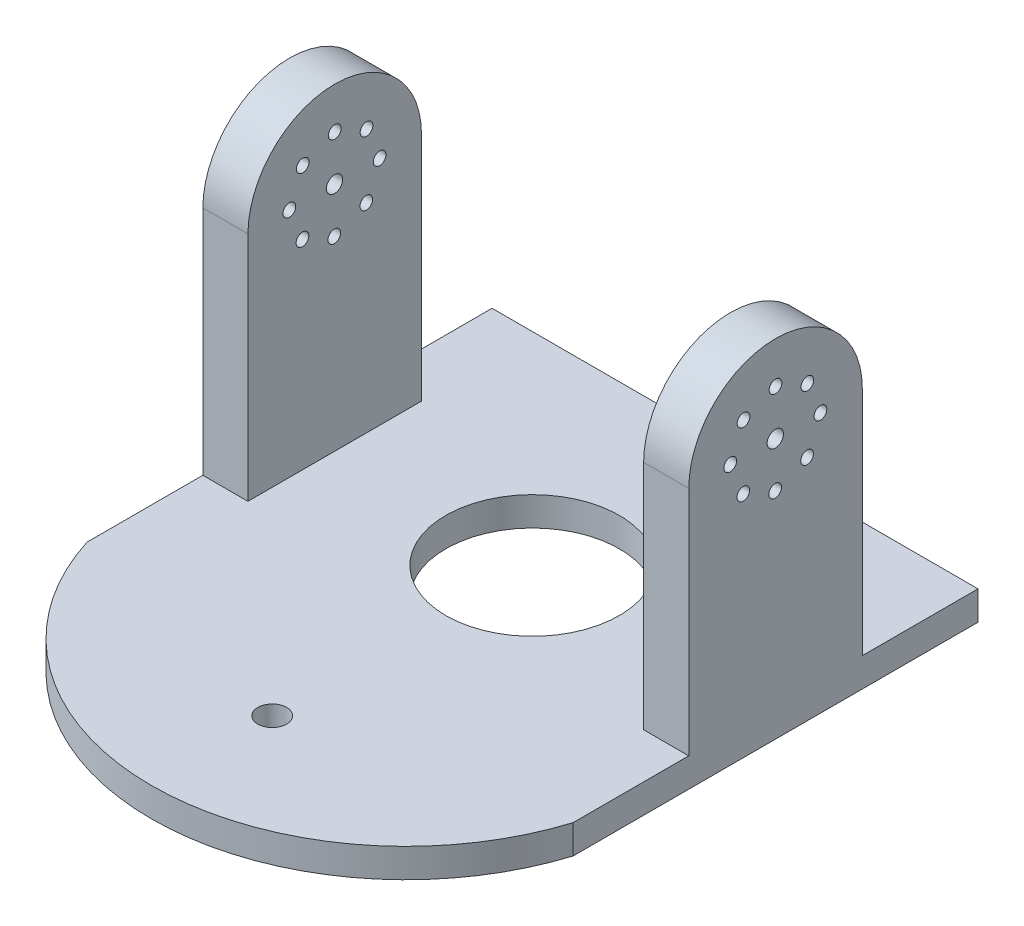
from build123d import *

# Parameters (mm, degrees)
SKETCH1_R           = 19.05
SKETCH1_R_2         = 3.175
BOSS_EXTRUDE1_DEPTH = 6.35
SKETCH6_W           = 9.906
SKETCH6_H           = 38.1
BOSS_EXTRUDE2_DEPTH = 76.2
SKETCH7_R           = 1.397
SKETCH7_R_2         = 1.7859375
CUT_EXTRUDE1_DEPTH  = 107.68


with BuildPart() as part:
    # Sketch1 → Boss-Extrude1 (new body)
    with BuildSketch(Plane(origin=(0, 0, 0), x_dir=(1, 0, 0), z_dir=(0, 1, 0))):
        with BuildLine():
            Line((-53.503176773, 44.45), (53.176823227, 44.45))
            Line((53.176823227, 44.45), (53.176823227, -44.45))
            ThreePointArc((53.176823227, -44.45), (-0.163176773, -83.674106148), (-53.503176773, -44.45))
            Line((-53.503176773, -44.45), (-53.503176773, 44.45))
        make_face()
        with Locations((-0.163176773, 0)):
            Circle(SKETCH1_R, mode=Mode.SUBTRACT)
        with Locations((-0.163176773, -57.15)):
            Circle(SKETCH1_R_2, mode=Mode.SUBTRACT)
    extrude(amount=BOSS_EXTRUDE1_DEPTH)

    # Sketch6 → Boss-Extrude2 (add)
    with BuildSketch(Plane(origin=(0, 6.35, 0), x_dir=(1, 0, 0), z_dir=(0, 1, 0))):
        with Locations((-48.550176773, 0)):
            Rectangle(SKETCH6_W, SKETCH6_H)
        with Locations((48.223823227, 0)):
            Rectangle(SKETCH6_W, SKETCH6_H)
    extrude(amount=BOSS_EXTRUDE2_DEPTH)

    # Sketch7 → Cut-Extrude1 (cut, through all)
    with BuildSketch(Plane.ZY.offset(53.503176773)):
        with Locations((-6.991480211, 64.122926346)):
            Circle(SKETCH7_R)
        with Locations((0, 67.056)):
            Circle(SKETCH7_R)
        with Locations((7.017719338, 64.186273203)):
            Circle(SKETCH7_R)
        with Locations((9.950792993, 57.194792993)):
            Circle(SKETCH7_R)
        with Locations((7.081066196, 50.177073654)):
            Circle(SKETCH7_R)
        with Locations((0.089585985, 47.244)):
            Circle(SKETCH7_R)
        with Locations((-6.928133353, 50.113726797)):
            Circle(SKETCH7_R)
        with Locations((-9.861207007, 57.105207007)):
            Circle(SKETCH7_R)
        with Locations((0.044792993, 57.15)):
            Circle(SKETCH7_R_2)
        with BuildLine():
            Line((-19.05, 57.105207007), (-19.05, 82.55))
            Line((-19.05, 82.55), (19.05, 82.55))
            Line((19.05, 82.55), (19.05, 57.194792993))
            ThreePointArc((19.05, 57.194792993), (-0.044687793, 76.155259669), (-19.05, 57.105207007))
        make_face()
    extrude(amount=-CUT_EXTRUDE1_DEPTH, mode=Mode.SUBTRACT)


solid = part.part
